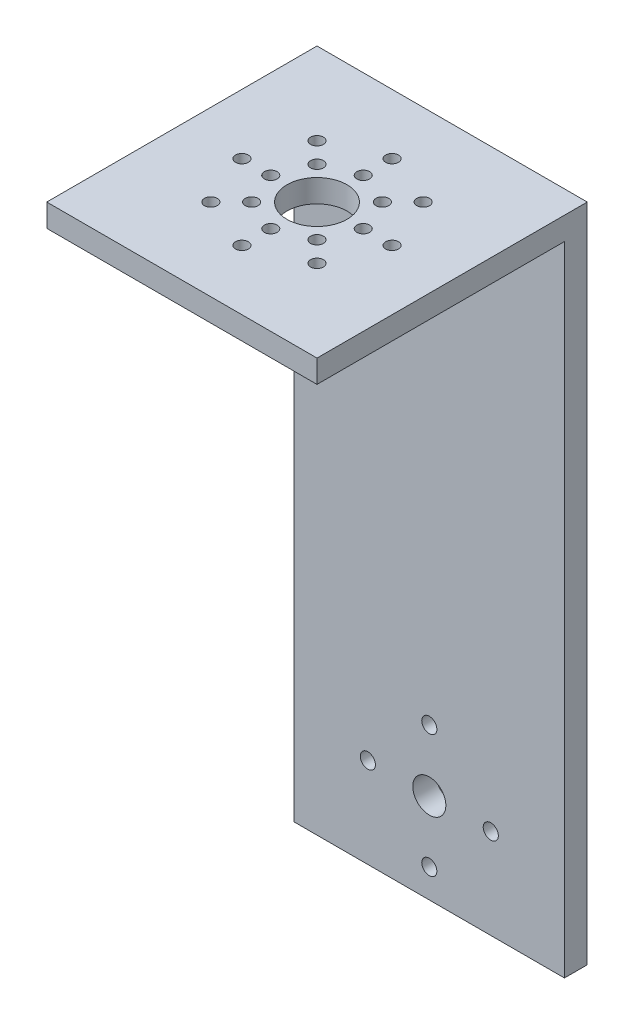
from build123d import *

# Parameters (mm, degrees)
EXTRUDE_THIN1_DEPTH             = 57.15
M2_5_CLEARANCE_HOLE1_AT_2_COUNT = 2
M2_5_CLEARANCE_HOLE1_AT_2_PITCH = 6.096
CUT_EXTRUDE1_REACH              = 141.7
SKETCH2_R                       = 6.35
CIRPATTERN1_COUNT               = 8
CUT_EXTRUDE2_REACH              = 59.15
SKETCH5_R                       = 3.5
CIRPATTERN2_COUNT               = 4


with BuildPart() as part:
    # Sketch1 → Extrude-Thin1 (new body)
    with BuildSketch(Plane(origin=(0, 0, 0), x_dir=(0, 0, -1), z_dir=(1, 0, 0))):
        Polygon((0, 0), (57.15, 0), (57.15, -139.7), (52.324, -139.7), (52.324, -4.826), (0, -4.826), align=None)
    extrude(amount=EXTRUDE_THIN1_DEPTH)

    # Sketch4 → M2.5 Clearance Hole1 (revolve, cut)
    with BuildSketch(Plane(origin=(17.349679849, 0, -39.800320151), x_dir=(0, 0, 1), z_dir=(1, 0, 0))):
        Polygon((0, 0), (0, 5.89269403), (1.35255, 5.08), (1.35255, 0), align=None)
    m2_5_clearance_hole1 = revolve(axis=Axis((17.349679849, 6.35, -39.800320151), (0, -1, 0)), mode=Mode.SUBTRACT)

    # M2.5 Clearance Hole1 at 2: M2.5 Clearance Hole1 ×2
    with Locations(*[Vector(0.707106781, 0, 0.707106781) * (i * M2_5_CLEARANCE_HOLE1_AT_2_PITCH) for i in range(1, M2_5_CLEARANCE_HOLE1_AT_2_COUNT)]):
        add(m2_5_clearance_hole1, mode=Mode.SUBTRACT)

    # Sketch2 → Cut-Extrude1 (cut, up to next)
    with BuildSketch(Plane(origin=(0, 0, 0), x_dir=(1, 0, 0), z_dir=(0, 1, 0)), mode=Mode.PRIVATE) as cut_extrude1_sk1:
        with Locations((28.575, 28.575)):
            Circle(SKETCH2_R)
    cut_extrude1_tool1 = extrude(cut_extrude1_sk1.sketch, amount=-CUT_EXTRUDE1_REACH, mode=Mode.PRIVATE) & part.part
    add(cut_extrude1_tool1.solids().sort_by_distance((28.575, 0, -28.575))[0], mode=Mode.SUBTRACT)

    # CirPattern1: M2.5 Clearance Hole1 ×8 about axis
    cirpattern1_axis = Axis((28.575, 0, -28.575), (0, 1, 0))
    for i in range(1, CIRPATTERN1_COUNT):
        add(m2_5_clearance_hole1.rotate(cirpattern1_axis, i * 360 / CIRPATTERN1_COUNT), mode=Mode.SUBTRACT)

    # CirPattern1 copy 1 sketch → CirPattern1 copy 1 (revolve, cut)
    with BuildSketch(Plane(origin=(18.796, 0, -28.575), x_dir=(0.707106781, 0, 0.707106781), z_dir=(0.707106781, 0, -0.707106781))):
        Polygon((0, 0), (0, 5.89269403), (1.35255, 5.08), (1.35255, 0), align=None)
    revolve(axis=Axis((18.796, 6.35, -28.575), (0, -1, 0)), mode=Mode.SUBTRACT)

    # CirPattern1 copy 2 sketch → CirPattern1 copy 2 (revolve, cut)
    with BuildSketch(Plane(origin=(21.660202787, 0, -21.660202787), x_dir=(1, 0, 0), z_dir=(0, 0, -1))):
        Polygon((0, 0), (0, 5.89269403), (1.35255, 5.08), (1.35255, 0), align=None)
    revolve(axis=Axis((21.660202787, 6.35, -21.660202787), (0, -1, 0)), mode=Mode.SUBTRACT)

    # CirPattern1 copy 3 sketch → CirPattern1 copy 3 (revolve, cut)
    with BuildSketch(Plane(origin=(28.575, 0, -18.796), x_dir=(0.707106781, 0, -0.707106781), z_dir=(-0.707106781, 0, -0.707106781))):
        Polygon((0, 0), (0, 5.89269403), (1.35255, 5.08), (1.35255, 0), align=None)
    revolve(axis=Axis((28.575, 6.35, -18.796), (0, -1, 0)), mode=Mode.SUBTRACT)

    # CirPattern1 copy 4 sketch → CirPattern1 copy 4 (revolve, cut)
    with BuildSketch(Plane(origin=(35.489797213, 0, -21.660202787), x_dir=(0, 0, -1), z_dir=(-1, 0, 0))):
        Polygon((0, 0), (0, 5.89269403), (1.35255, 5.08), (1.35255, 0), align=None)
    revolve(axis=Axis((35.489797213, 6.35, -21.660202787), (0, -1, 0)), mode=Mode.SUBTRACT)

    # CirPattern1 copy 5 sketch → CirPattern1 copy 5 (revolve, cut)
    with BuildSketch(Plane(origin=(38.354, 0, -28.575), x_dir=(-0.707106781, 0, -0.707106781), z_dir=(-0.707106781, 0, 0.707106781))):
        Polygon((0, 0), (0, 5.89269403), (1.35255, 5.08), (1.35255, 0), align=None)
    revolve(axis=Axis((38.354, 6.35, -28.575), (0, -1, 0)), mode=Mode.SUBTRACT)

    # CirPattern1 copy 6 sketch → CirPattern1 copy 6 (revolve, cut)
    with BuildSketch(Plane(origin=(35.489797213, 0, -35.489797213), x_dir=(-1, 0, 0), z_dir=(0, 0, 1))):
        Polygon((0, 0), (0, 5.89269403), (1.35255, 5.08), (1.35255, 0), align=None)
    revolve(axis=Axis((35.489797213, 6.35, -35.489797213), (0, -1, 0)), mode=Mode.SUBTRACT)

    # CirPattern1 copy 7 sketch → CirPattern1 copy 7 (revolve, cut)
    with BuildSketch(Plane(origin=(28.575, 0, -38.354), x_dir=(-0.707106781, 0, 0.707106781), z_dir=(0.707106781, 0, 0.707106781))):
        Polygon((0, 0), (0, 5.89269403), (1.35255, 5.08), (1.35255, 0), align=None)
    revolve(axis=Axis((28.575, 6.35, -38.354), (0, -1, 0)), mode=Mode.SUBTRACT)

    # Sketch5 → Cut-Extrude2 (cut, up to next)
    with BuildSketch(Plane(origin=(0, 0, -57.15), x_dir=(-1, 0, 0), z_dir=(0, 0, -1)), mode=Mode.PRIVATE) as cut_extrude2_sk1:
        with Locations((-28.575, -120.65)):
            Circle(SKETCH5_R)
    cut_extrude2_tool1 = extrude(cut_extrude2_sk1.sketch, amount=-CUT_EXTRUDE2_REACH, mode=Mode.PRIVATE) & part.part
    add(cut_extrude2_tool1.solids().sort_by_distance((28.575, -120.65, -57.15))[0], mode=Mode.SUBTRACT)

    # Sketch7 → M3 Clearance Hole1 (revolve, cut)
    with BuildSketch(Plane(origin=(28.575, -107.65, -57.15), x_dir=(0, 1, 0), z_dir=(1, 0, 0))):
        Polygon((0, 0), (0, 6.04137699), (1.6, 5.08), (1.6, 0), align=None)
    m3_clearance_hole1 = revolve(axis=Axis((28.575, -107.65, -63.5), (0, 0, 1)), mode=Mode.SUBTRACT)

    # CirPattern2: M3 Clearance Hole1 ×4 about axis
    cirpattern2_axis = Axis((28.575, -120.65, 0), (0, 0, 1))
    for i in range(1, CIRPATTERN2_COUNT):
        add(m3_clearance_hole1.rotate(cirpattern2_axis, i * 360 / CIRPATTERN2_COUNT), mode=Mode.SUBTRACT)


solid = part.part
